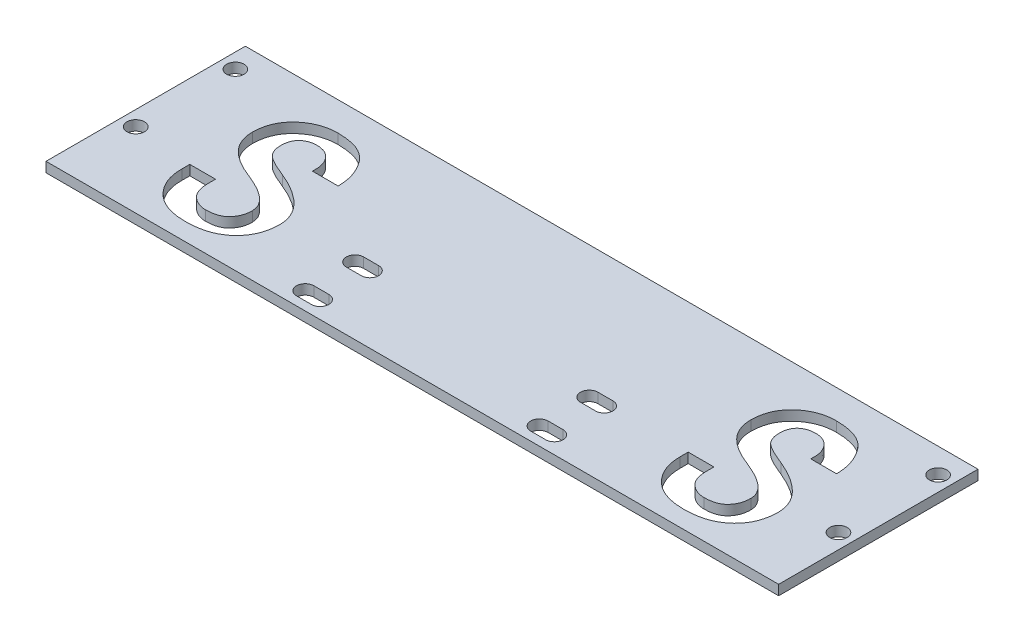
from build123d import *

# Parameters (mm, degrees)
SKETCH_1_W             = 147
SKETCH_1_H             = 62
EXTRUDE_1_DEPTH        = 2
SKETCH_2_R             = 1.75
CUT_EXTRUDE_1_DEPTH    = 3
CUT_EXTRUDE_2_DEPTH    = 3
PATTERN_LINEAR_1_COUNT = 2
PATTERN_LINEAR_1_PITCH = 100
SKETCH_5_W             = 147
SKETCH_5_H             = 12
CUT_EXTRUDE_3_DEPTH    = 10
SKETCH_6_W             = 147
SKETCH_6_H             = 10
CUT_EXTRUDE_4_DEPTH    = 3.0000001


with BuildPart() as part:
    # 草图1 → 凸台-拉伸1 (new body)
    with BuildSketch(Plane(origin=(0, 0, 0), x_dir=(1, 0, 0), z_dir=(0, 1, 0))):
        Rectangle(SKETCH_1_W, SKETCH_1_H)
    extrude(amount=EXTRUDE_1_DEPTH)

    # 草图2 → 切除-拉伸1 (cut, through all)
    with BuildSketch(Plane(origin=(0, 2, 0), x_dir=(1, 0, 0), z_dir=(0, 1, 0))):
        with Locations((70.5, 26)):
            Circle(SKETCH_2_R)
        with Locations((70.5, 6)):
            Circle(SKETCH_2_R)
        with Locations((-70.5, 6)):
            Circle(SKETCH_2_R)
        with Locations((-70.5, 26)):
            Circle(SKETCH_2_R)
        with BuildLine():
            Line((25, 2.75), (22, 2.75))
            ThreePointArc((22, 2.75), (20.25, 4.5), (22, 6.25))
            Line((22, 6.25), (25, 6.25))
            ThreePointArc((25, 6.25), (26.75, 4.5), (25, 2.75))
        make_face()
        with BuildLine():
            Line((25, -7.25), (22, -7.25))
            ThreePointArc((22, -7.25), (20.25, -5.5), (22, -3.75))
            Line((22, -3.75), (25, -3.75))
            ThreePointArc((25, -3.75), (26.75, -5.5), (25, -7.25))
        make_face()
        with BuildLine():
            Line((-25, 6.25), (-22, 6.25))
            ThreePointArc((-22, 6.25), (-20.25, 4.5), (-22, 2.75))
            Line((-22, 2.75), (-25, 2.75))
            ThreePointArc((-25, 2.75), (-26.75, 4.5), (-25, 6.25))
        make_face()
        with BuildLine():
            Line((-25, -3.75), (-22, -3.75))
            ThreePointArc((-22, -3.75), (-20.25, -5.5), (-22, -7.25))
            Line((-22, -7.25), (-25, -7.25))
            ThreePointArc((-25, -7.25), (-26.75, -5.5), (-25, -3.75))
        make_face()
    extrude(amount=-CUT_EXTRUDE_1_DEPTH, mode=Mode.SUBTRACT)

    # 草图4 → 切除-拉伸2 (cut, through all)
    with BuildSketch(Plane(origin=(0, 2, 0), x_dir=(1, 0, 0), z_dir=(0, 1, 0))):
        with BuildLine():
            add(Edge.make_bspline(
                [(-39.052640052, 3.459111397), (-39.058369557, 3.134485778), (-39.069573508, 2.499685809), (-39.20716373, 1.571503364), (-39.407794521, 0.687890094), (-39.698960301, -0.151313593), (-40.081216996, -0.937541442), (-40.543847982, -1.679319302), (-41.084711671, -2.376992748), (-41.710243203, -3.018519724), (-42.40552293, -3.602873847), (-43.177518422, -4.101391158), (-44.003746629, -4.539384071), (-44.899858501, -4.884788429), (-45.857043879, -5.155597162), (-46.878608498, -5.346226122), (-47.963791317, -5.464238672), (-48.708906443, -5.477871883), (-49.091274952, -5.484867997)],
                knots=[0, 0, 0, 0, 0.000973079, 0.00190284, 0.002808748, 0.003688488, 0.004561105, 0.005425896, 0.006306907, 0.007203985, 0.008109229, 0.009025423, 0.009955719, 0.010909931, 0.011900556, 0.012936118, 0.014024087, 0.015170907, 0.015170907, 0.015170907, 0.015170907], degree=3))
            add(Edge.make_bspline(
                [(-49.091274952, -5.484867997), (-49.452148543, -5.477681287), (-50.15439285, -5.463696262), (-51.178662613, -5.348466302), (-52.140153201, -5.14566059), (-53.047381711, -4.881290156), (-53.889510929, -4.522191278), (-54.672957737, -4.091733666), (-55.39323464, -3.577970108), (-56.047336774, -2.992876771), (-56.633791332, -2.349333159), (-57.14166411, -1.658829103), (-57.57924822, -0.932083834), (-57.933716898, -0.16570247), (-58.204057156, 0.642977557), (-58.405780726, 1.486900198), (-58.522226887, 2.374074041), (-58.536622683, 2.977986443), (-58.543947199, 3.285254346)],
                knots=[0, 0, 0, 0, 0.001082467, 0.002106433, 0.003086412, 0.004027586, 0.00493651, 0.005827117, 0.006704402, 0.00758459, 0.008455209, 0.009311641, 0.010152018, 0.01099616, 0.011839173, 0.012705998, 0.013595743, 0.014517352, 0.014517352, 0.014517352, 0.014517352], degree=3))
            Line((-58.543947199, 3.285254346), (-58.543947199, 4.895041854))
            Line((-58.543947199, 4.895041854), (-53.386188023, 4.895041854))
            Line((-53.386188023, 4.895041854), (-53.386188023, 3.459111397))
            add(Edge.make_bspline(
                [(-53.386188023, 3.459111397), (-53.383423595, 3.257122844), (-53.37805586, 2.864918472), (-53.309652798, 2.297047005), (-53.213281206, 1.769151363), (-53.059670981, 1.285669052), (-52.876698183, 0.841289348), (-52.64863858, 0.436265481), (-52.378778084, 0.071715989), (-51.959752201, -0.337177959), (-51.393865186, -0.765456011), (-50.663501807, -1.144646376), (-49.888461762, -1.376123297), (-49.358965873, -1.406438322), (-49.091274952, -1.421764327)],
                knots=[0, 0, 0, 0, 0.000605588, 0.00117588, 0.001713848, 0.00221283, 0.002694778, 0.003153226, 0.003603966, 0.004050177, 0.0049053, 0.005723173, 0.00650772, 0.007309904, 0.007309904, 0.007309904, 0.007309904], degree=3))
            add(Edge.make_bspline(
                [(-49.091274952, -1.421764327), (-48.887183553, -1.418848681), (-48.490783462, -1.413185717), (-47.918028418, -1.347037182), (-47.386301513, -1.244000561), (-46.895752768, -1.107853689), (-46.453304281, -0.915783887), (-46.049223431, -0.693425746), (-45.693011786, -0.418166347), (-45.273810404, -0.00718262), (-44.848818139, 0.581537554), (-44.471688178, 1.363023538), (-44.247439774, 2.219039657), (-44.222925822, 2.813875954), (-44.210399227, 3.117836446)],
                knots=[0, 0, 0, 0, 0.000612024, 0.001188715, 0.001726682, 0.002236149, 0.002712167, 0.003170615, 0.003616221, 0.004057901, 0.004928521, 0.005778148, 0.006649624, 0.007560303, 0.007560303, 0.007560303, 0.007560303], degree=3))
            add(Edge.make_bspline(
                [(-44.210399227, 3.117836446), (-44.228107098, 3.3713406), (-44.26407227, 3.886214501), (-44.555566237, 4.636143402), (-45.020548732, 5.354499761), (-45.666698974, 6.048250594), (-46.499019173, 6.717867372), (-47.520188972, 7.372305262), (-48.733228928, 8.015077749), (-49.624707921, 8.396174408), (-50.095782357, 8.597553123)],
                knots=[0, 0, 0, 0, 0.000758755, 0.001541052, 0.002380614, 0.003314913, 0.004371895, 0.005577461, 0.006948622, 0.008485044, 0.008485044, 0.008485044, 0.008485044], degree=3))
            add(Edge.make_bspline(
                [(-50.095782357, 8.597553123), (-50.420717881, 8.724276127), (-51.051047469, 8.970101076), (-51.957443743, 9.362881779), (-52.796405032, 9.773917055), (-53.565795517, 10.205293917), (-54.274376418, 10.642522568), (-54.911499077, 11.098308084), (-55.480987494, 11.570353775), (-55.988097607, 12.053676722), (-56.43012449, 12.560043129), (-56.812588478, 13.089907572), (-57.134480822, 13.644949813), (-57.40183212, 14.221991999), (-57.607837187, 14.824164701), (-57.758106492, 15.451152199), (-57.839745622, 16.103456029), (-57.854126841, 16.545405867), (-57.861397296, 16.768834514)],
                knots=[0, 0, 0, 0, 0.001046258, 0.002029594, 0.002962627, 0.003847606, 0.004674855, 0.005459322, 0.006195557, 0.006892325, 0.007558645, 0.008209127, 0.008849685, 0.009480656, 0.010113955, 0.010755871, 0.01141159, 0.012082035, 0.012082035, 0.012082035, 0.012082035], degree=3))
            add(Edge.make_bspline(
                [(-57.861397296, 16.768834514), (-57.854888287, 17.076199384), (-57.842179305, 17.676336032), (-57.715934644, 18.554606861), (-57.510187166, 19.387077648), (-57.227222302, 20.175639013), (-56.863597772, 20.920869342), (-56.409442545, 21.615542826), (-55.878697264, 22.26950188), (-55.274550152, 22.871327736), (-54.614877656, 23.413671401), (-53.919137638, 23.894179165), (-53.186368296, 24.294637326), (-52.424961062, 24.622728984), (-51.635209477, 24.884742442), (-50.812510311, 25.061845116), (-49.961545118, 25.174810008), (-49.383542066, 25.190000724), (-49.091274952, 25.197681906)],
                knots=[0, 0, 0, 0, 0.000921609, 0.001799461, 0.002655287, 0.003490393, 0.004308241, 0.005136967, 0.005974676, 0.006830671, 0.007690581, 0.008533593, 0.009363544, 0.010191295, 0.011018017, 0.011855429, 0.012712416, 0.013588993, 0.013588993, 0.013588993, 0.013588993], degree=3))
            add(Edge.make_bspline(
                [(-49.091274952, 25.197681906), (-48.691610753, 25.189847692), (-47.919883564, 25.174720302), (-46.80821522, 25.036193906), (-45.782604815, 24.821110361), (-44.844675183, 24.515547854), (-43.997169023, 24.111688171), (-43.236607803, 23.623708933), (-42.573362621, 23.034895433), (-42.001247394, 22.368510737), (-41.514705479, 21.646538537), (-41.078529213, 20.907160502), (-40.716381676, 20.141393851), (-40.421440657, 19.356866262), (-40.186843504, 18.552146108), (-40.018450017, 17.725530427), (-39.921487548, 16.876349594), (-39.908920603, 16.303309122), (-39.902607856, 16.01545396)],
                knots=[0, 0, 0, 0, 0.00119853, 0.002314288, 0.003354963, 0.004338468, 0.005265884, 0.006164255, 0.007040169, 0.007916698, 0.008791878, 0.00964889, 0.010489933, 0.011329495, 0.012160919, 0.013001961, 0.0138574, 0.014720846, 0.014720846, 0.014720846, 0.014720846], degree=3))
            Line((-39.902607856, 16.01545396), (-45.066806182, 16.01545396))
            add(Edge.make_bspline(
                [(-45.066806182, 16.01545396), (-45.052831539, 16.35928789), (-45.026034294, 17.018610809), (-45.17686294, 17.971123639), (-45.483215411, 18.831897231), (-45.887168456, 19.454486535), (-46.261636877, 19.896074742), (-46.579788807, 20.182538663), (-46.931328895, 20.41917896), (-47.303750362, 20.623392349), (-47.711079501, 20.770041853), (-48.144616473, 20.878408904), (-48.607903385, 20.953714064), (-48.927842071, 20.958352005), (-49.091274952, 20.960721185)],
                knots=[0, 0, 0, 0, 0.001030284, 0.001975634, 0.002874005, 0.003751101, 0.004184825, 0.004608881, 0.005030387, 0.005453856, 0.005879668, 0.006324762, 0.00679376, 0.007283517, 0.007283517, 0.007283517, 0.007283517], degree=3))
            add(Edge.make_bspline(
                [(-49.091274952, 20.960721185), (-49.347801419, 20.950691102), (-49.841538806, 20.931386166), (-50.545199872, 20.752313123), (-51.174530729, 20.46045226), (-51.724370571, 20.051610916), (-52.172682082, 19.521927782), (-52.483768758, 18.867967488), (-52.670755406, 18.107735312), (-52.692285523, 17.56415263), (-52.70363812, 17.277527366)],
                knots=[0, 0, 0, 0, 0.000768447, 0.001479033, 0.002161735, 0.002837846, 0.003518845, 0.004221509, 0.004991439, 0.005850263, 0.005850263, 0.005850263, 0.005850263], degree=3))
            add(Edge.make_bspline(
                [(-52.70363812, 17.277527366), (-52.694859761, 17.036217322), (-52.677795165, 16.567125222), (-52.513806065, 15.896734294), (-52.242925054, 15.29284039), (-51.936599202, 14.829239016), (-51.593788704, 14.491731789), (-51.252585868, 14.224475838), (-50.819873845, 13.94947614), (-50.308375423, 13.653288618), (-49.704235915, 13.355474427), (-49.024755096, 13.03056598), (-48.252892036, 12.704823924), (-47.709329272, 12.485966039), (-47.423535093, 12.370895042)],
                knots=[0, 0, 0, 0, 0.000723022, 0.001405511, 0.002054078, 0.002702421, 0.003057568, 0.003493009, 0.004000232, 0.004594451, 0.005265421, 0.006020094, 0.006853759, 0.007778063, 0.007778063, 0.007778063, 0.007778063], degree=3))
            add(Edge.make_bspline(
                [(-47.423535093, 12.370895042), (-47.091696211, 12.232170663), (-46.443603977, 11.961237397), (-45.514245945, 11.51430336), (-44.646804381, 11.051726155), (-43.835107674, 10.576208915), (-43.090628387, 10.072151393), (-42.400550799, 9.559453363), (-41.769329724, 9.0294592), (-41.205275974, 8.476697911), (-40.697866174, 7.909369824), (-40.260504815, 7.322029978), (-39.881551375, 6.722198139), (-39.578482564, 6.102180775), (-39.34435864, 5.465250275), (-39.177603497, 4.811599022), (-39.069303002, 4.140976723), (-39.058210015, 3.687040114), (-39.052640052, 3.459111397)],
                knots=[0, 0, 0, 0, 0.00107886, 0.00210705, 0.00309224, 0.004027602, 0.004927702, 0.005787974, 0.006605847, 0.007398151, 0.008155347, 0.008886835, 0.009592591, 0.010280857, 0.010953124, 0.011624681, 0.012302232, 0.012985541, 0.012985541, 0.012985541, 0.012985541], degree=3))
        make_face()
    cut_extrude_2 = extrude(amount=-CUT_EXTRUDE_2_DEPTH, mode=Mode.SUBTRACT)

    # 阵列(线性)1: 切除-拉伸2 ×2
    with Locations(*[(i * PATTERN_LINEAR_1_PITCH, 0, 0) for i in range(1, PATTERN_LINEAR_1_COUNT)]):
        add(cut_extrude_2, mode=Mode.SUBTRACT)

    # 草图5 → 切除-拉伸3 (cut)
    with BuildSketch(Plane(origin=(0, 2, 0), x_dir=(1, 0, 0), z_dir=(0, 1, 0))):
        with Locations((0, -25)):
            Rectangle(SKETCH_5_W, SKETCH_5_H)
    extrude(amount=-CUT_EXTRUDE_3_DEPTH, mode=Mode.SUBTRACT)

    # 草图6 → 切除-拉伸4 (cut, through all)
    with BuildSketch(Plane(origin=(0, 2, 0), x_dir=(1, 0, 0), z_dir=(0, 1, 0))):
        with Locations((0, -14)):
            Rectangle(SKETCH_6_W, SKETCH_6_H)
    extrude(amount=-CUT_EXTRUDE_4_DEPTH, mode=Mode.SUBTRACT)


solid = part.part
